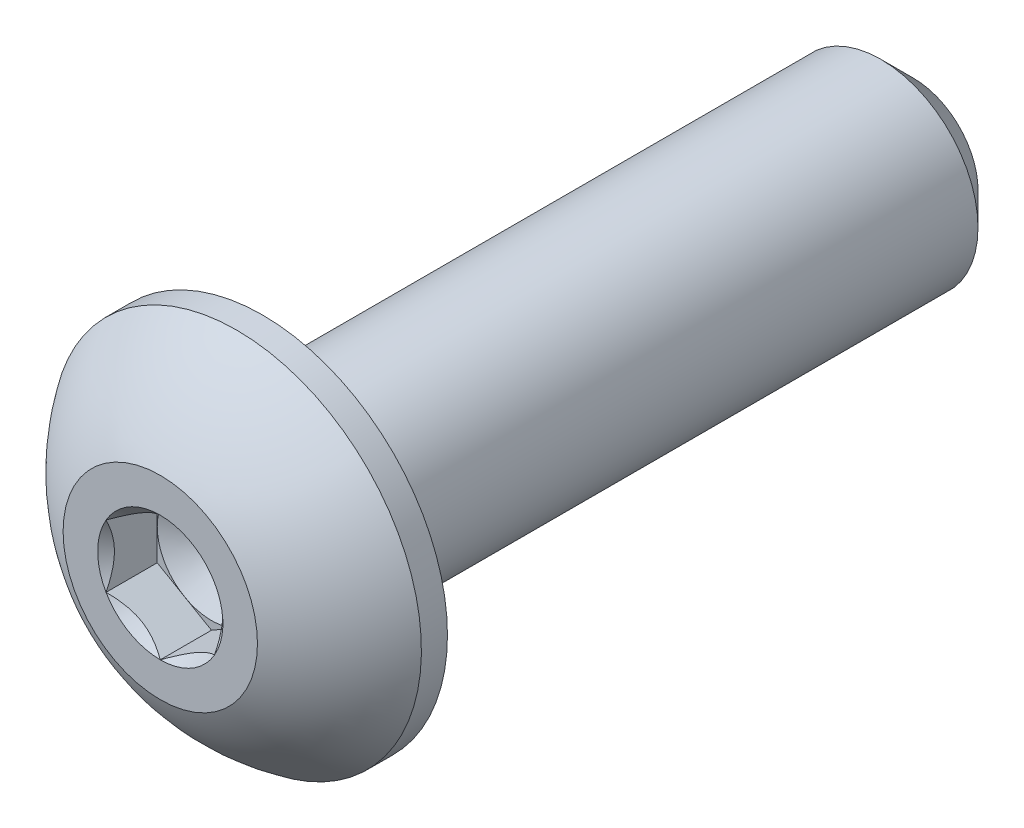
from build123d import *

# Parameters (mm, degrees)
SKETCH1_W          = 9.525
SKETCH1_H          = 1.4224
CHAMFER1_SIZE      = 0.47625
SKETCH4_R          = 2.7051
EXTRUDE1_DEPTH     = 1.4986
CUT_EXTRUDE1_DEPTH = 0.7493
SKETCH7_R          = 0.916543552
CUT_EXTRUDE4_DEPTH = 0.7493
CUT_EXTRUDE4_TAPER = 45
SKETCH8_R          = 0.79375
CUT_EXTRUDE5_DEPTH = 0.249766667
CUT_EXTRUDE5_TAPER = 60


with BuildPart() as part:
    # Sketch1 → Revolve1 (revolve)
    with BuildSketch(Plane(origin=(0, 0, 0), x_dir=(0, 0, -1), z_dir=(1, 0, 0))):
        with Locations((4.7625, 0.7112)):
            Rectangle(SKETCH1_W, SKETCH1_H)
    revolve(axis=Axis((0, 0, 0), (0, 0, 1)))

    # Chamfer1
    chamfer1_edges = [part.edges().sort_by_distance(p)[0] for p in [
        (0, -1.4224, -9.525),
    ]]
    chamfer(chamfer1_edges, length=CHAMFER1_SIZE)

    # Sketch4 → Extrude1 (add)
    with BuildSketch(Plane.XY):
        Circle(SKETCH4_R)
    extrude(amount=EXTRUDE1_DEPTH)

    # Sketch9 → Cut-Revolve3 (revolve, cut)
    with BuildSketch(Plane(origin=(0, 0, 0), x_dir=(0, 0, -1), z_dir=(1, 0, 0))):
        with BuildLine():
            Line((0, 2.7051), (-0.381, 2.7051))
            ThreePointArc((-0.381, 2.7051), (-1.025093234, 2.138064897), (-1.4986, 1.4224))
            Line((-1.4986, 1.4224), (-1.8796, 1.4224))
            Line((-1.8796, 1.4224), (-1.8796, 3.0861))
            Line((-1.8796, 3.0861), (0, 3.0861))
            Line((0, 3.0861), (0, 2.7051))
        make_face()
    revolve(axis=Axis((0, 0, 0), (0, 0, 1)), mode=Mode.SUBTRACT)

    # Sketch6 → Cut-Extrude1 (cut)
    with BuildSketch(Plane.XY.offset(1.4986)):
        Polygon((0, -0.916543552), (0.79375, -0.458271776), (0.79375, 0.458271776), (0, 0.916543552), (-0.79375, 0.458271776), (-0.79375, -0.458271776), align=None)
    extrude(amount=-CUT_EXTRUDE1_DEPTH, mode=Mode.SUBTRACT)

    # Sketch7 → Cut-Extrude4 (cut)
    with BuildSketch(Plane.XY.offset(1.4986)):
        Circle(SKETCH7_R)
    extrude(amount=-CUT_EXTRUDE4_DEPTH, taper=CUT_EXTRUDE4_TAPER, mode=Mode.SUBTRACT)

    # Sketch8 → Cut-Extrude5 (cut)
    with BuildSketch(Plane.XY.offset(0.7493)):
        Circle(SKETCH8_R)
    extrude(amount=-CUT_EXTRUDE5_DEPTH, taper=CUT_EXTRUDE5_TAPER, mode=Mode.SUBTRACT)


solid = part.part
